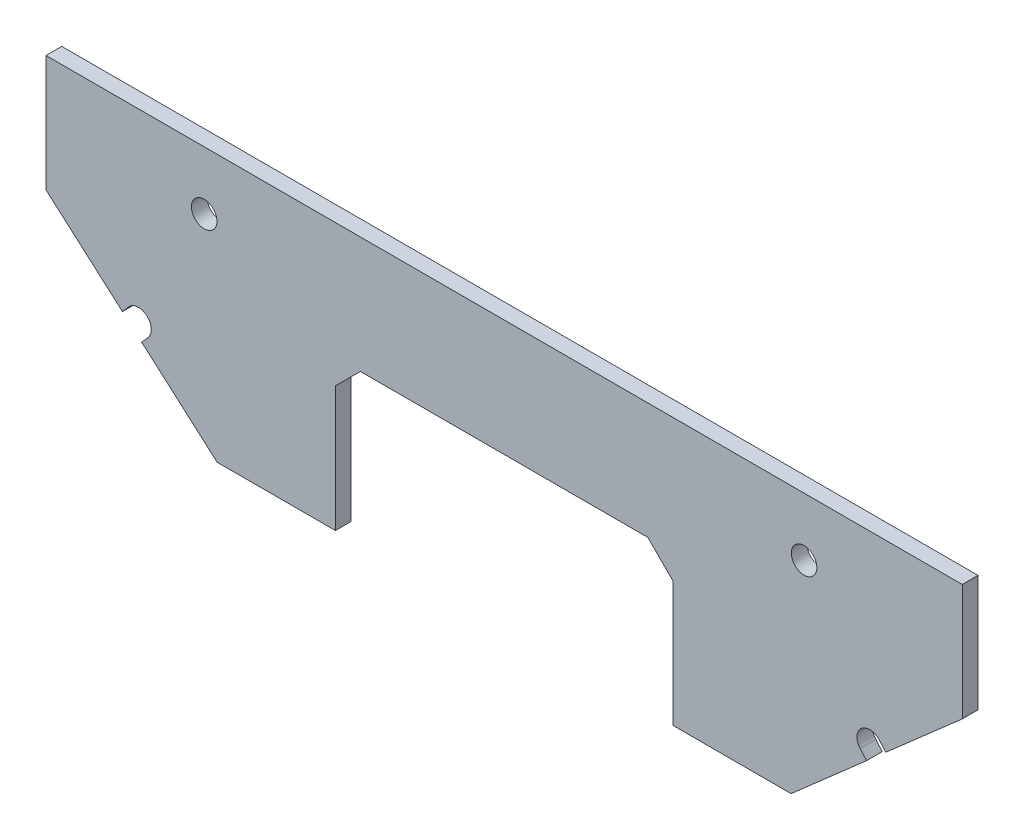
from build123d import *

# Parameters (mm, degrees)
SKETCH1_W                  = 93.116399905
SKETCH1_H                  = 11.836399908
BOSS_EXTRUDE1_DEPTH        = 1.6002
BOSS_EXTRUDE2_DEPTH        = 1.6002
CHAMFER1_SIZE              = 2.54
F_2_6_2_6_DIAMETER_HOLE1_D = 2.6
CUT_EXTRUDE1_DEPTH         = 2.6002


with BuildPart() as part:
    # Sketch1 → Boss-Extrude1 (new body)
    with BuildSketch(Plane.XY.offset(1.63)):
        with Locations((-40.639999999, 0)):
            Rectangle(SKETCH1_W, SKETCH1_H)
    extrude(amount=BOSS_EXTRUDE1_DEPTH)

    # Sketch4 → Boss-Extrude2 (add, through all)
    with BuildSketch(Plane(origin=(0, 0, 1.63), x_dir=(-1, 0, 0), z_dir=(0, 0, -1))):
        Polygon((87.198199951, -5.918199954), (69.803821783, -21.189450144), (57.785000156, -21.189450144), (57.785000156, -5.918199954), align=None)
        Polygon((-5.918199954, -5.918199954), (23.494999841, -5.918199954), (23.494999841, -21.189450144), (11.476178214, -21.189450144), align=None)
    extrude(amount=-BOSS_EXTRUDE2_DEPTH)

    # Chamfer1
    chamfer1_edges = [part.edges().sort_by_distance(p)[0] for p in [
        (-57.785000156, -5.918199954, 2.4301),
        (-23.494999841, -5.918199954, 2.4301),
    ]]
    chamfer(chamfer1_edges, length=CHAMFER1_SIZE)

    # Ø2.6 (2.6) Diameter Hole1 (through all)
    with Locations(Plane.XY.offset(3.2302)):
        with Locations((-10.160000092, -7.6e-08), (-71.119999812, -3.5e-08), (-77.798317195, -12.855075132), (-3.481682742, -12.855075132)):
            Hole(F_2_6_2_6_DIAMETER_HOLE1_D / 2)

    # Sketch6 → Cut-Extrude1 (cut, through all)
    with BuildSketch(Plane(origin=(0, 0, 1.63), x_dir=(-1, 0, 0), z_dir=(0, 0, -1))):
        Polygon((79.427543726, -12.740383202), (78.775241344, -11.997392669), (76.821393045, -13.712757594), (77.473695428, -14.455748127), align=None)
        Polygon((1.852456271, -12.740383202), (3.806304569, -14.455748127), (4.458606952, -13.712757594), (2.504758653, -11.997392669), align=None)
    extrude(amount=-CUT_EXTRUDE1_DEPTH, mode=Mode.SUBTRACT)


solid = part.part
